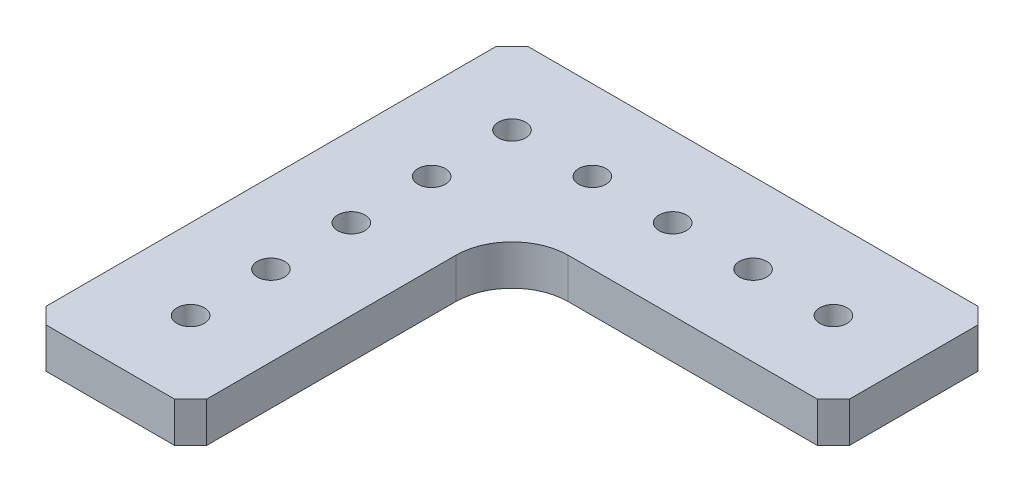
from build123d import *

# Parameters (mm, degrees)
BOSS_EXTRUDE1_DEPTH = 6.35
CHAMFER9_SIZE       = 2.54
CHAMFER10_SIZE      = 2.54
CHAMFER11_SIZE      = 2.54
CHAMFER12_SIZE      = 2.54
CHAMFER13_SIZE      = 2.54
FILLET1_R           = 8.89
SKETCH2_R           = 2.159
CUT_EXTRUDE1_DEPTH  = 7.35


with BuildPart() as part:
    # Sketch1 → Boss-Extrude1 (new body)
    with BuildSketch(Plane(origin=(0, 0, 0), x_dir=(1, 0, 0), z_dir=(0, 1, 0))):
        Polygon((-45.908148148, -30.432962963), (-20.508148148, -30.432962963), (-20.508148148, 20.367037037), (30.291851852, 20.367037037), (30.291851852, 45.767037037), (-20.508148148, 45.767037037), (-45.908148148, 45.767037037), (-45.908148148, 20.367037037), align=None)
    extrude(amount=BOSS_EXTRUDE1_DEPTH)

    # Chamfer9
    chamfer9_edges = [part.edges().sort_by_distance(p)[0] for p in [
        (-20.508148148, 3.175, 30.432962963),
    ]]
    chamfer(chamfer9_edges, length=CHAMFER9_SIZE)

    # Chamfer10
    chamfer10_edges = [part.edges().sort_by_distance(p)[0] for p in [
        (30.291851852, 3.175, -20.367037037),
    ]]
    chamfer(chamfer10_edges, length=CHAMFER10_SIZE)

    # Chamfer11
    chamfer11_edges = [part.edges().sort_by_distance(p)[0] for p in [
        (30.291851852, 3.175, -45.767037037),
    ]]
    chamfer(chamfer11_edges, length=CHAMFER11_SIZE)

    # Chamfer12
    chamfer12_edges = [part.edges().sort_by_distance(p)[0] for p in [
        (-45.908148148, 3.175, 30.432962963),
    ]]
    chamfer(chamfer12_edges, length=CHAMFER12_SIZE)

    # Chamfer13
    chamfer13_edges = [part.edges().sort_by_distance(p)[0] for p in [
        (-45.908148148, 3.175, -45.767037037),
    ]]
    chamfer(chamfer13_edges, length=CHAMFER13_SIZE)

    # Fillet1
    fillet1_edges = [part.edges().sort_by_distance(p)[0] for p in [
        (-20.508148148, 3.175, -20.367037037),
    ]]
    fillet(fillet1_edges, radius=FILLET1_R)

    # Sketch2 → Cut-Extrude1 (cut, through all)
    with BuildSketch(Plane(origin=(0, 6.35, 0), x_dir=(1, 0, 0), z_dir=(0, 1, 0))):
        with Locations((-33.208148148, 33.067037037)):
            Circle(SKETCH2_R)
        with Locations((-20.508148148, 33.067037037)):
            Circle(SKETCH2_R)
        with Locations((-7.808148148, 33.067037037)):
            Circle(SKETCH2_R)
        with Locations((4.891851852, 33.067037037)):
            Circle(SKETCH2_R)
        with Locations((17.591851852, 33.067037037)):
            Circle(SKETCH2_R)
        with Locations((-33.208148148, 20.367037037)):
            Circle(SKETCH2_R)
        with Locations((-33.208148148, 7.667037037)):
            Circle(SKETCH2_R)
        with Locations((-33.208148148, -5.032962963)):
            Circle(SKETCH2_R)
        with Locations((-33.208148148, -17.732962963)):
            Circle(SKETCH2_R)
    extrude(amount=-CUT_EXTRUDE1_DEPTH, mode=Mode.SUBTRACT)


solid = part.part
